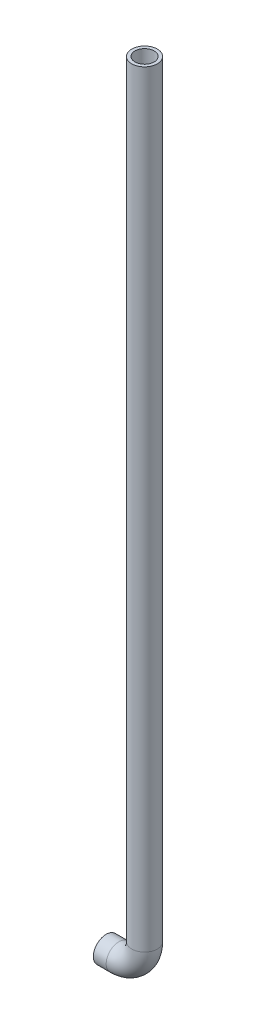
from build123d import *

# Parameters (mm, degrees)
SWEEP1_PROFILE_R = 12.7
SHELL2_T         = -3.175


with BuildPart() as part:
    # Sweep1: sweep along a path in Sketch1
    with BuildLine(Plane.XY) as sweep1_path:
        Line((38.1, 786.13), (38.1, 25.4))
        ThreePointArc((38.1, 25.4), (30.660512242, 7.439487758), (12.7, 0))
        Line((12.7, 0), (0, 0))
    # Sweep1 profile (on start of the path) → Sweep1 (sweep)
    with BuildSketch(Plane(origin=(38.1, 786.13, 0), x_dir=(-1, 0, 0), z_dir=(0, -1, 0))):
        Circle(SWEEP1_PROFILE_R)
    sweep(path=sweep1_path.line)

    # Shell2
    shell2_openings = [part.faces().sort_by_distance(p)[0] for p in [
        (0, 0, 0),
        (38.1, 786.13, 0),
    ]]
    offset(amount=SHELL2_T, openings=shell2_openings, kind=Kind.INTERSECTION)


solid = part.part
